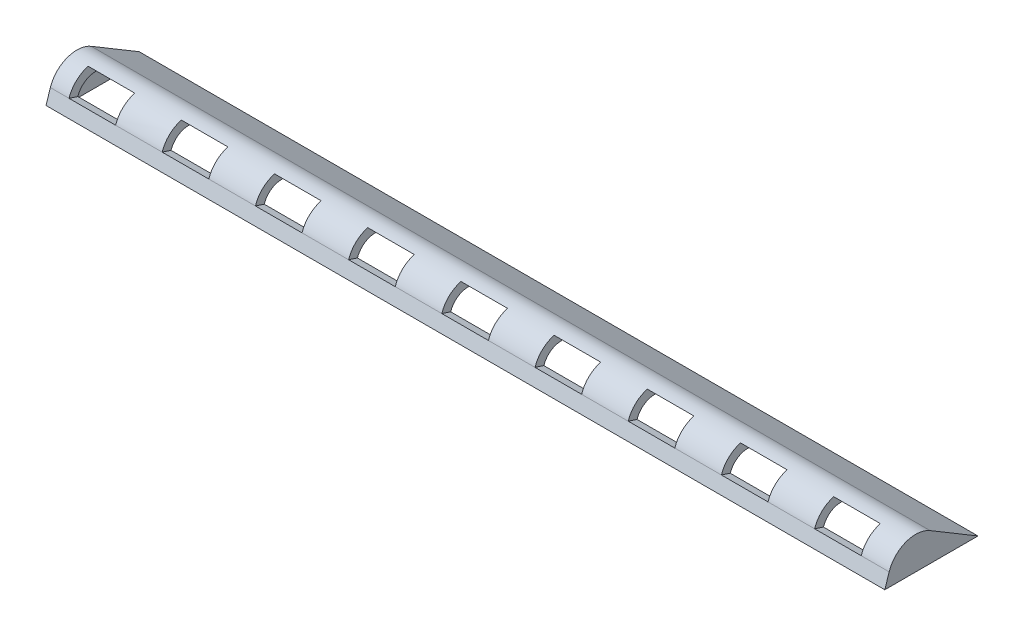
from build123d import *

# Parameters (mm, degrees)
BOSS_EXTRUDE1_DEPTH = 90
SHELL1_T            = -1
SKETCH2_W           = 5
SKETCH2_H           = 2.5
CUT_EXTRUDE2_DEPTH  = 3


with BuildPart() as part:
    # Sketch1 → Boss-Extrude1 (new body)
    with BuildSketch(Plane(origin=(0, 0, 0), x_dir=(0, 0, -1), z_dir=(1, 0, 0))):
        with BuildLine():
            Line((0, 0), (0.468395453, 1.431403189))
            ThreePointArc((0.468395453, 1.431403189), (2.268780711, 3.308334479), (4.858963514, 3.073363867))
            Line((4.858963514, 3.073363867), (10, 0))
            Line((10, 0), (0, 0))
        make_face()
    extrude(amount=BOSS_EXTRUDE1_DEPTH)

    # Shell1
    shell1_openings = [part.faces().sort_by_distance(p)[0] for p in [
        (45, 0, -5),
    ]]
    offset(amount=SHELL1_T, openings=shell1_openings, kind=Kind.INTERSECTION)

    # Sketch2 → Cut-Extrude2 (cut)
    with BuildSketch(Plane(origin=(0, 0, 0), x_dir=(1, 0, 0), z_dir=(0, 0.311000813, 0.950409645))):
        with Locations((4.5, 2.756090765)):
            Rectangle(SKETCH2_W, SKETCH2_H)
        with Locations((14.5, 2.756090765)):
            Rectangle(SKETCH2_W, SKETCH2_H)
        with Locations((24.5, 2.756090765)):
            Rectangle(SKETCH2_W, SKETCH2_H)
        with Locations((34.5, 2.756090765)):
            Rectangle(SKETCH2_W, SKETCH2_H)
        with Locations((44.5, 2.756090765)):
            Rectangle(SKETCH2_W, SKETCH2_H)
        with Locations((54.5, 2.756090765)):
            Rectangle(SKETCH2_W, SKETCH2_H)
        with Locations((64.5, 2.756090765)):
            Rectangle(SKETCH2_W, SKETCH2_H)
        with Locations((74.5, 2.756090765)):
            Rectangle(SKETCH2_W, SKETCH2_H)
        with Locations((84.5, 2.756090765)):
            Rectangle(SKETCH2_W, SKETCH2_H)
    extrude(amount=-CUT_EXTRUDE2_DEPTH, mode=Mode.SUBTRACT)


solid = part.part
